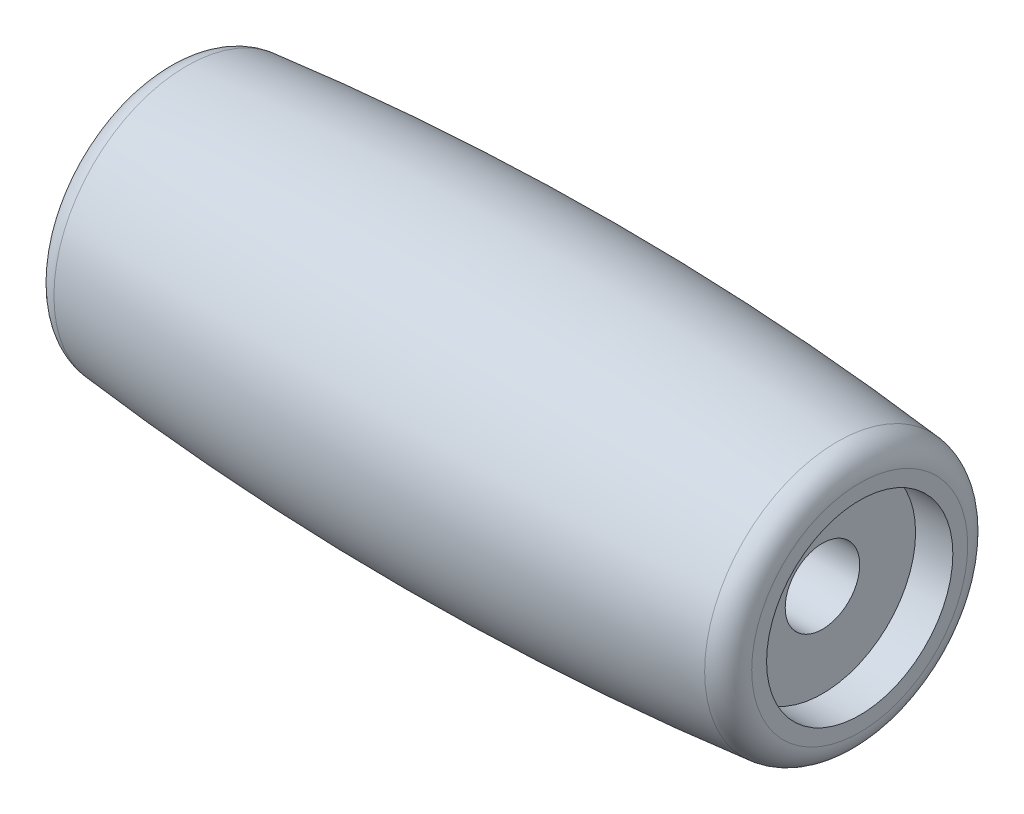
from build123d import *

# Parameters (mm, degrees)
SCALE1_SCALE = 2


with BuildPart() as part:
    # Sketch1 → Revolve1 (revolve)
    with BuildSketch(Plane.XY):
        with BuildLine():
            Line((14, 3.75), (14, 4.348576665))
            ThreePointArc((14, 4.348576665), (13.741609048, 5.019408999), (13.099967959, 5.343567322))
            ThreePointArc((13.099967959, 5.343567322), (0, 6), (-13.099967959, 5.343567322))
            ThreePointArc((-13.099967959, 5.343567322), (-13.741609048, 5.019408999), (-14, 4.348576665))
            Line((-14, 4.348576665), (-14, 3.75))
            Line((-14, 3.75), (-12.5, 3.75))
            Line((-12.5, 3.75), (-12.5, 1.5))
            Line((-12.5, 1.5), (-9.090776518, 1.5))
            Line((-9.090776518, 1.5), (9.090776518, 1.5))
            Line((9.090776518, 1.5), (12.5, 1.5))
            Line((12.5, 1.5), (12.5, 3.75))
            Line((12.5, 3.75), (14, 3.75))
        make_face()
    revolve(axis=Axis((-14, 0, 0), (1, 0, 0)))


with BuildPart() as part_1:
    # Scale1: scaled about (0, 0, 0)
    add(part.part.scale(SCALE1_SCALE))


solid = part_1.part
